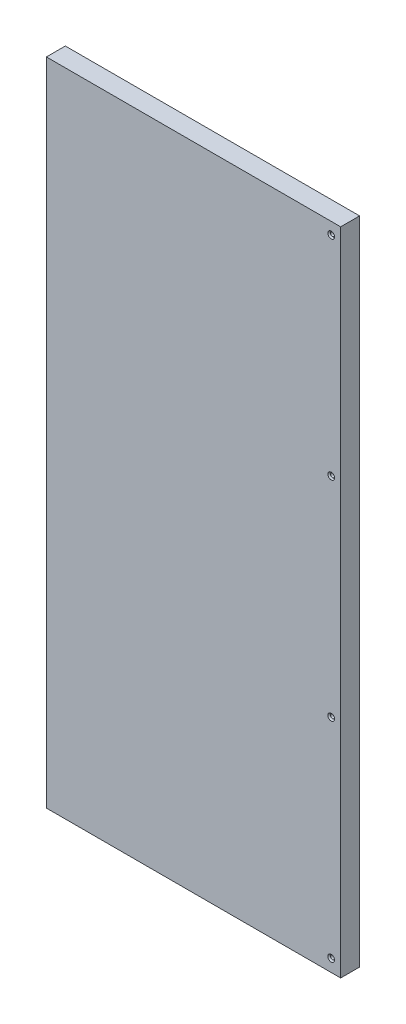
from build123d import *

# Parameters (mm, degrees)
SKETCH1_W                                         = 248.78
SKETCH1_H                                         = 550
BOSS_EXTRUDE1_DEPTH                               = 16
CSK_FOR_4_FLAT_HEAD_MACHINE_SCREW_100_D           = 3.2639
CSK_FOR_4_FLAT_HEAD_MACHINE_SCREW_100_DEPTH       = 16
CSK_FOR_4_FLAT_HEAD_MACHINE_SCREW_100_CSINK_D     = 5.715
CSK_FOR_4_FLAT_HEAD_MACHINE_SCREW_100_CSINK_ANGLE = 100
LPATTERN1_COUNT                                   = 4
LPATTERN1_PITCH                                   = 176.5


with BuildPart() as part:
    # Sketch1 → Boss-Extrude1 (new body)
    with BuildSketch(Plane.XY):
        Rectangle(SKETCH1_W, SKETCH1_H)
    extrude(amount=BOSS_EXTRUDE1_DEPTH)

    # CSK for #4 Flat Head Machine Screw (100)1
    with Locations(Plane.XY.offset(16)):
        with Locations((116.39, -264.5)):
            csk_for_4_flat_head_machine_screw_100 = CounterSinkHole(CSK_FOR_4_FLAT_HEAD_MACHINE_SCREW_100_D / 2, CSK_FOR_4_FLAT_HEAD_MACHINE_SCREW_100_CSINK_D / 2, depth=CSK_FOR_4_FLAT_HEAD_MACHINE_SCREW_100_DEPTH, counter_sink_angle=CSK_FOR_4_FLAT_HEAD_MACHINE_SCREW_100_CSINK_ANGLE)

    # LPattern1: CSK for #4 Flat Head Machine Screw (100)1 ×4
    with Locations(*[(0, i * LPATTERN1_PITCH, 0) for i in range(1, LPATTERN1_COUNT)]):
        add(csk_for_4_flat_head_machine_screw_100, mode=Mode.SUBTRACT)


solid = part.part
